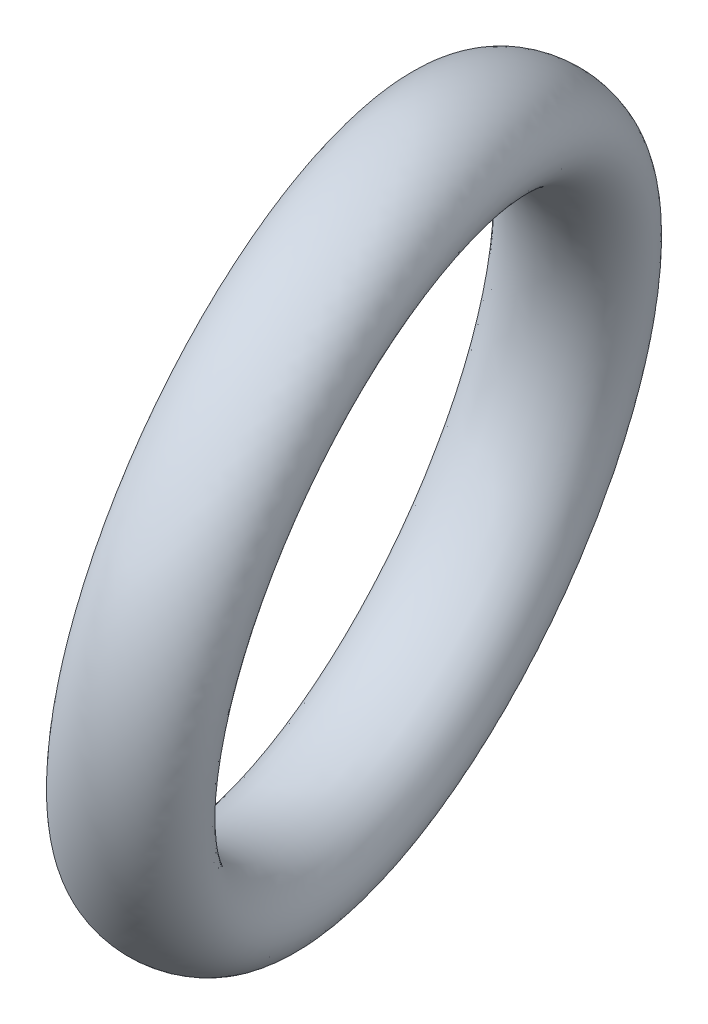
from build123d import *

# Parameters (mm, degrees)
SKETCH6_RX = 47.5
SKETCH6_RY = 35


with BuildPart() as part:
    # Sketch6 → Revolve1 (revolve)
    with BuildSketch(Plane(origin=(24.783171522, 259.691030023, -57.440630795), x_dir=(-1, 0, 0), z_dir=(0, -0.866025404, 0.5))):
        with Locations(Location((67.546671815, 218.31427519), (0, 0, 162.807876266))):
            Ellipse(SKETCH6_RX, SKETCH6_RY)
    revolve(axis=Axis((24.783171522, 259.691030023, -57.440630795), (-0.955319003, 0.147788364, 0.255976955)))


solid = part.part
